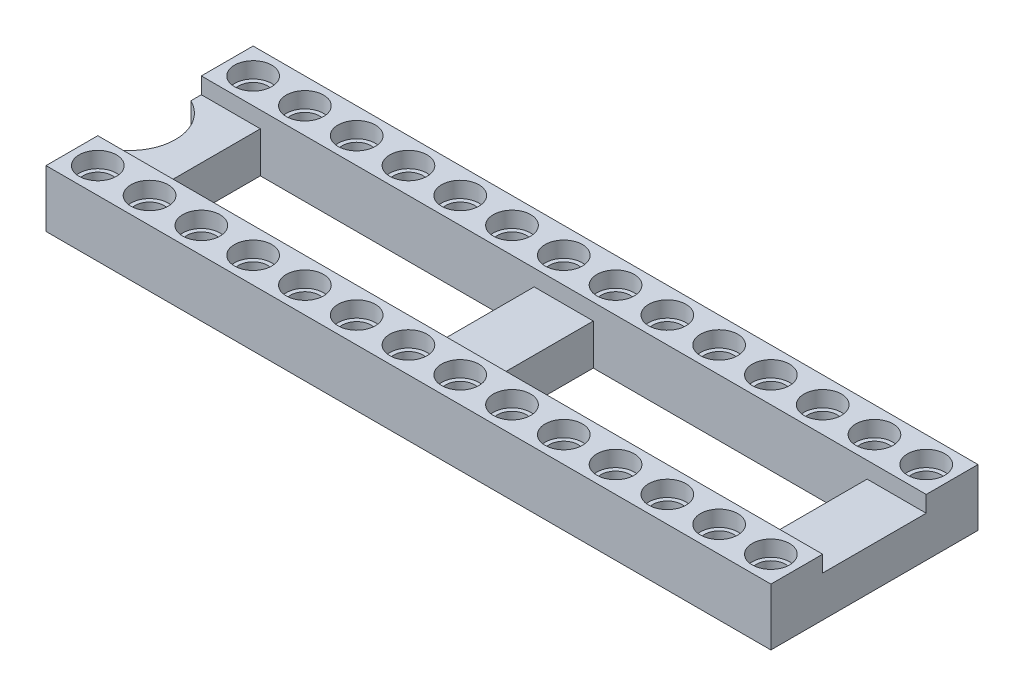
from build123d import *

# Parameters (mm, degrees)
SKETCH1_W           = 35.56
SKETCH1_H           = 10.16
BOSS_EXTRUDE1_DEPTH = 2.8
SKETCH3_R           = 0.915
CUT_EXTRUDE1_DEPTH  = 0.78
SKETCH4_W           = 35.56
SKETCH4_H           = 5.08
CUT_EXTRUDE2_DEPTH  = 0.8
SKETCH5_R           = 2.25
SKETCH5_W           = 13.4325
SKETCH5_H           = 5.08
CUT_EXTRUDE3_DEPTH  = 3
SKETCH6_R           = 0.71
CUT_EXTRUDE4_DEPTH  = 3.02


with BuildPart() as part:
    # Sketch1 → Boss-Extrude1 (new body)
    with BuildSketch(Plane(origin=(0, 0, 0), x_dir=(1, 0, 0), z_dir=(0, 1, 0))):
        with Locations((17.78, 5.08)):
            Rectangle(SKETCH1_W, SKETCH1_H)
    extrude(amount=BOSS_EXTRUDE1_DEPTH)

    # Sketch3 → Cut-Extrude1 (cut)
    with BuildSketch(Plane(origin=(0, 2.8, 0), x_dir=(1, 0, 0), z_dir=(0, 1, 0))):
        with Locations((1.27, 8.89)):
            Circle(SKETCH3_R)
        with Locations((3.81, 8.89)):
            Circle(SKETCH3_R)
        with Locations((6.35, 8.89)):
            Circle(SKETCH3_R)
        with Locations((8.89, 8.89)):
            Circle(SKETCH3_R)
        with Locations((11.43, 8.89)):
            Circle(SKETCH3_R)
        with Locations((13.97, 8.89)):
            Circle(SKETCH3_R)
        with Locations((16.51, 8.89)):
            Circle(SKETCH3_R)
        with Locations((19.05, 8.89)):
            Circle(SKETCH3_R)
        with Locations((21.59, 8.89)):
            Circle(SKETCH3_R)
        with Locations((24.13, 8.89)):
            Circle(SKETCH3_R)
        with Locations((26.67, 8.89)):
            Circle(SKETCH3_R)
        with Locations((29.21, 8.89)):
            Circle(SKETCH3_R)
        with Locations((31.75, 8.89)):
            Circle(SKETCH3_R)
        with Locations((34.29, 8.89)):
            Circle(SKETCH3_R)
        with Locations((3.81, 1.27)):
            Circle(SKETCH3_R)
        with Locations((6.35, 1.27)):
            Circle(SKETCH3_R)
        with Locations((8.89, 1.27)):
            Circle(SKETCH3_R)
        with Locations((11.43, 1.27)):
            Circle(SKETCH3_R)
        with Locations((13.97, 1.27)):
            Circle(SKETCH3_R)
        with Locations((16.51, 1.27)):
            Circle(SKETCH3_R)
        with Locations((19.05, 1.27)):
            Circle(SKETCH3_R)
        with Locations((21.59, 1.27)):
            Circle(SKETCH3_R)
        with Locations((24.13, 1.27)):
            Circle(SKETCH3_R)
        with Locations((26.67, 1.27)):
            Circle(SKETCH3_R)
        with Locations((29.21, 1.27)):
            Circle(SKETCH3_R)
        with Locations((31.75, 1.27)):
            Circle(SKETCH3_R)
        with Locations((34.29, 1.27)):
            Circle(SKETCH3_R)
        with Locations((1.27, 1.27)):
            Circle(SKETCH3_R)
    extrude(amount=-CUT_EXTRUDE1_DEPTH, mode=Mode.SUBTRACT)

    # Sketch4 → Cut-Extrude2 (cut)
    with BuildSketch(Plane(origin=(0, 2.8, 0), x_dir=(1, 0, 0), z_dir=(0, 1, 0))):
        with Locations((17.78, 5.08)):
            Rectangle(SKETCH4_W, SKETCH4_H)
    extrude(amount=-CUT_EXTRUDE2_DEPTH, mode=Mode.SUBTRACT)

    # Sketch5 → Cut-Extrude3 (cut, through all)
    with BuildSketch(Plane(origin=(0, 2, 0), x_dir=(1, 0, 0), z_dir=(0, 1, 0))):
        with Locations((-0.98, 5.08)):
            Circle(SKETCH5_R)
        with Locations((9.61125, 5.08)):
            Rectangle(SKETCH5_W, SKETCH5_H)
        with Locations((25.94375, 5.08)):
            Rectangle(SKETCH5_W, SKETCH5_H)
    extrude(amount=-CUT_EXTRUDE3_DEPTH, mode=Mode.SUBTRACT)

    # Sketch6 → Cut-Extrude4 (cut, through all)
    with BuildSketch(Plane(origin=(0, 2.02, 0), x_dir=(1, 0, 0), z_dir=(0, 1, 0))):
        with Locations((1.27, 8.89)):
            Circle(SKETCH6_R)
        with Locations((3.81, 8.89)):
            Circle(SKETCH6_R)
        with Locations((6.35, 8.89)):
            Circle(SKETCH6_R)
        with Locations((8.89, 8.89)):
            Circle(SKETCH6_R)
        with Locations((11.43, 8.89)):
            Circle(SKETCH6_R)
        with Locations((13.97, 8.89)):
            Circle(SKETCH6_R)
        with Locations((16.51, 8.89)):
            Circle(SKETCH6_R)
        with Locations((19.05, 8.89)):
            Circle(SKETCH6_R)
        with Locations((21.59, 8.89)):
            Circle(SKETCH6_R)
        with Locations((24.13, 8.89)):
            Circle(SKETCH6_R)
        with Locations((26.67, 8.89)):
            Circle(SKETCH6_R)
        with Locations((29.21, 8.89)):
            Circle(SKETCH6_R)
        with Locations((31.75, 8.89)):
            Circle(SKETCH6_R)
        with Locations((34.29, 8.89)):
            Circle(SKETCH6_R)
        with Locations((3.81, 1.27)):
            Circle(SKETCH6_R)
        with Locations((6.35, 1.27)):
            Circle(SKETCH6_R)
        with Locations((8.89, 1.27)):
            Circle(SKETCH6_R)
        with Locations((11.43, 1.27)):
            Circle(SKETCH6_R)
        with Locations((13.97, 1.27)):
            Circle(SKETCH6_R)
        with Locations((16.51, 1.27)):
            Circle(SKETCH6_R)
        with Locations((19.05, 1.27)):
            Circle(SKETCH6_R)
        with Locations((21.59, 1.27)):
            Circle(SKETCH6_R)
        with Locations((24.13, 1.27)):
            Circle(SKETCH6_R)
        with Locations((26.67, 1.27)):
            Circle(SKETCH6_R)
        with Locations((29.21, 1.27)):
            Circle(SKETCH6_R)
        with Locations((31.75, 1.27)):
            Circle(SKETCH6_R)
        with Locations((34.29, 1.27)):
            Circle(SKETCH6_R)
        with Locations((1.27, 1.27)):
            Circle(SKETCH6_R)
    extrude(amount=-CUT_EXTRUDE4_DEPTH, mode=Mode.SUBTRACT)


solid = part.part
